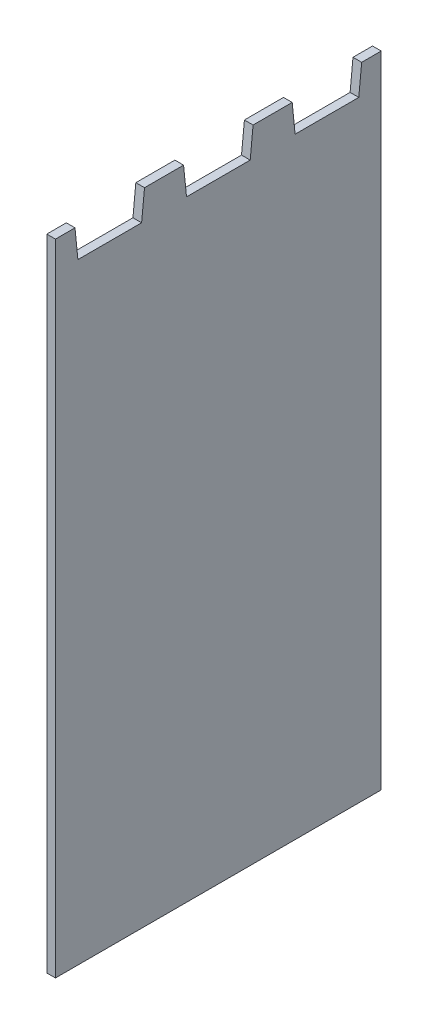
from build123d import *

# Parameters (mm, degrees)
SKETCH2_W           = 37.5
SKETCH2_H           = 206
BOSS_EXTRUDE2_DEPTH = 3
LPATTERN1_COUNT     = 3
LPATTERN1_PITCH     = 37.5


with BuildPart() as part:
    # Sketch2 → Boss-Extrude2 (new body)
    with BuildSketch(Plane(origin=(0, 0, 0), x_dir=(0, 0, -1), z_dir=(1, 0, 0))):
        Rectangle(SKETCH2_W, SKETCH2_H)
        Polygon((18.75, 118), (18.75, 103), (-18.75, 103), (-18.75, 118), (-12, 118), (-11, 108), (11, 108), (12, 118), align=None)
    boss_extrude2 = extrude(amount=BOSS_EXTRUDE2_DEPTH)

    # LPattern1: Boss-Extrude2 ×3
    with Locations(*[(0, 0, i * LPATTERN1_PITCH) for i in range(1, LPATTERN1_COUNT)]):
        add(boss_extrude2)


solid = part.part
